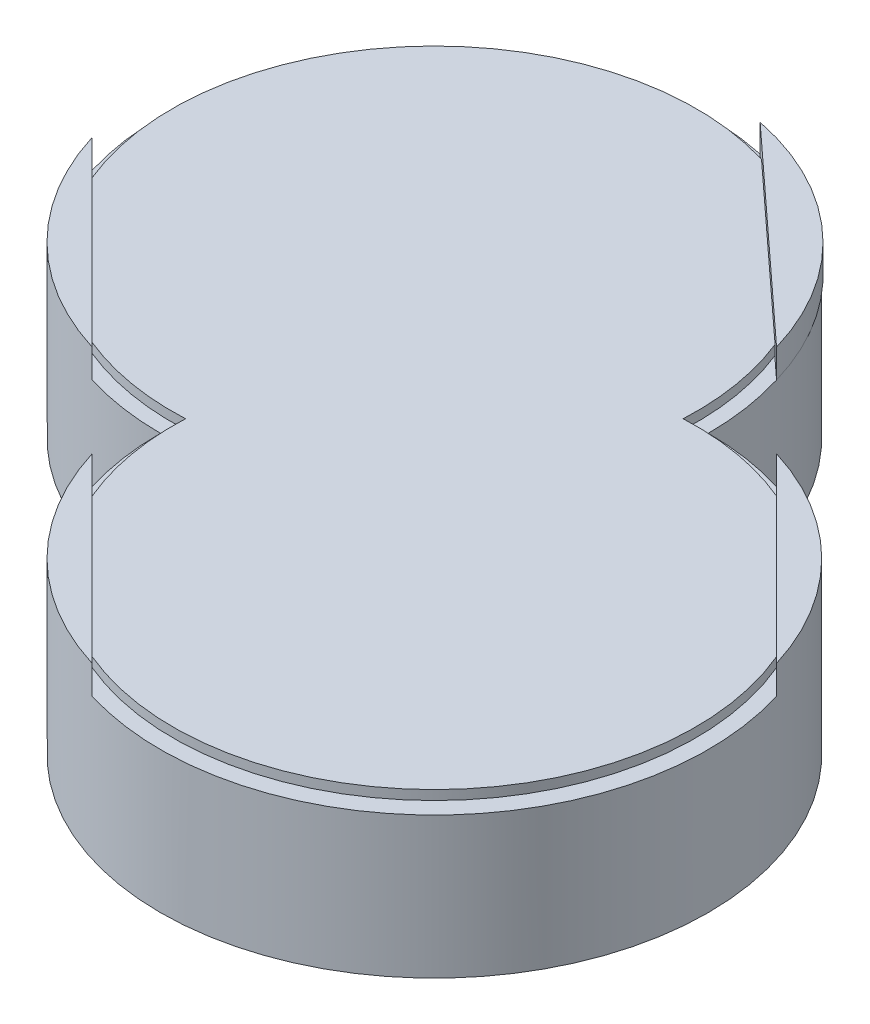
from build123d import *
from build123d.topology import SkipClean

# Parameters (mm, degrees)
BOSS_EXTRUDE1_DEPTH   = 24.13
SKETCH1_R             = 15.25707278
BOSS_EXTRUDE1_2_DEPTH = 24.13
SKETCH1_R_2           = 16.082263277
BOSS_EXTRUDE1_3_DEPTH = 24.13
BOSS_EXTRUDE2_START   = -6.096
BOSS_EXTRUDE2_DEPTH   = 6.096
BOSS_EXTRUDE3_DEPTH   = 6.096
CUT_EXTRUDE2_DEPTH    = 6.096
BOSS_EXTRUDE6_DEPTH   = 2.794
CUT_EXTRUDE3_DEPTH    = 0.762


with BuildPart() as part:
    # Sketch1 → Boss-Extrude1 (new body)
    with BuildSketch(Plane(origin=(0, 0, 0), x_dir=(1, 0, 0), z_dir=(0, 1, 0))):
        with BuildLine():
            ThreePointArc((0, 58.61646355), (-100.064562416, 100.064562416), (-58.61646355, 0))
            ThreePointArc((-58.61646355, 0), (41.448098866, -41.448098866), (0, 58.61646355))
        make_face()
        with BuildLine():
            ThreePointArc((0, 44.487942063), (31.457725514, -31.457725514), (-44.487942063, 0))
            Line((-44.487942063, 0), (-58.61646355, 14.199351912))
            ThreePointArc((-58.61646355, 14.199351912), (-90.024104391, 90.024104391), (-14.199351912, 58.61646355))
            Line((-14.199351912, 58.61646355), (0, 44.487942063))
        make_face(mode=Mode.SUBTRACT)
    extrude(amount=BOSS_EXTRUDE1_DEPTH)



with BuildPart() as body_2:
    # Sketch1 → Boss-Extrude1 2 (new body)
    with BuildSketch(Plane(origin=(0, 0, 0), x_dir=(1, 0, 0), z_dir=(0, 1, 0))):
        with Locations((-58.61646355, 58.61646355)):
            Circle(SKETCH1_R)
    extrude(amount=BOSS_EXTRUDE1_2_DEPTH)


with BuildPart() as body_3:
    # Sketch1 → Boss-Extrude1 3 (new body)
    with BuildSketch(Plane(origin=(0, 0, 0), x_dir=(1, 0, 0), z_dir=(0, 1, 0))):
        Circle(SKETCH1_R_2)
    extrude(amount=BOSS_EXTRUDE1_3_DEPTH)


with BuildPart() as part_1:
    add(part.part)

    add(body_2.part)  # Boss-Extrude2 merges body 2

    add(body_3.part)  # Boss-Extrude2 merges body 3
    # Sketch1_5 → Boss-Extrude2 (add)
    with BuildSketch(Plane(origin=(0, 0, 0), x_dir=(1, 0, 0), z_dir=(0, 1, 0)).offset(BOSS_EXTRUDE2_START)):
        with BuildLine():
            ThreePointArc((0, 58.61646355), (-100.064562416, 100.064562416), (-58.61646355, 0))
            ThreePointArc((-58.61646355, 0), (41.448098866, -41.448098866), (0, 58.61646355))
        make_face()
    extrude(amount=BOSS_EXTRUDE2_DEPTH)

    # Sketch5 → Boss-Extrude3 (add)
    with SkipClean():  # the faces are left unmerged after this step: merging them gives an invalid solid
        with BuildSketch(Plane(origin=(0, 24.13, 0), x_dir=(1, 0, 0), z_dir=(0, 1, 0))):
            with BuildLine():
                Line((-114.656096447, 41.427823582), (-75.805103519, 2.576830654))
                ThreePointArc((-75.805103519, 2.576830654), (-100.064562416, 17.168364685), (-114.656096447, 41.427823582))
            make_face()
            with BuildLine():
                Line((17.188639969, 56.039632897), (56.039632897, 17.188639969))
                ThreePointArc((56.039632897, 17.188639969), (41.448098866, 41.448098866), (17.188639969, 56.039632897))
            make_face()
            with BuildLine():
                Line((-45.993671494, 115.704154646), (-2.576830654, 75.805103519))
                ThreePointArc((-2.576830654, 75.805103519), (-18.713405445, 101.817729032), (-45.993671494, 115.704154646))
            make_face()
            with BuildLine():
                Line((-17.188639969, -56.039632897), (-56.039632897, -17.188639969))
                ThreePointArc((-56.039632897, -17.188639969), (-41.448098866, -41.448098866), (-17.188639969, -56.039632897))
            make_face()
        extrude(amount=BOSS_EXTRUDE3_DEPTH)

    # Sketch6 → Cut-Extrude2 (cut)
    with SkipClean():  # the faces are left unmerged after this step: merging them gives an invalid solid
        with BuildSketch(Plane(origin=(0, 24.13, 0), x_dir=(1, 0, 0), z_dir=(0, 1, 0))):
            with BuildLine():
                ThreePointArc((-9.489981352, 0), (-6.710430167, -6.710430167), (0, -9.489981352))
                ThreePointArc((0, -9.489981352), (5.668121673, -5.668121673), (9.489981352, 0))
                ThreePointArc((9.489981352, 0), (6.710430167, 6.710430167), (0, 9.489981352))
                ThreePointArc((0, 9.489981352), (-5.677482123, 5.677482123), (-9.489981352, 0))
            make_face()
            with BuildLine():
                ThreePointArc((-48.996622209, 58.61646355), (-51.814208504, 65.418718597), (-58.61646355, 68.236304892))
                ThreePointArc((-58.61646355, 68.236304892), (-64.379822748, 64.379822748), (-68.236304892, 58.61646355))
                ThreePointArc((-68.236304892, 58.61646355), (-65.418718597, 51.814208504), (-58.61646355, 48.996622209))
                ThreePointArc((-58.61646355, 48.996622209), (-52.847164261, 52.847164261), (-48.996622209, 58.61646355))
            make_face()
        extrude(amount=-CUT_EXTRUDE2_DEPTH, mode=Mode.SUBTRACT)

    # Sketch7 → Boss-Extrude6 (add)
    with SkipClean():  # the faces are left unmerged after this step: merging them gives an invalid solid
        with BuildSketch(Plane(origin=(0, 24.13, 0), x_dir=(1, 0, 0), z_dir=(0, 1, 0))):
            with BuildLine():
                ThreePointArc((-55.830465051, 2.585437245), (39.520408105, -39.520408105), (-2.585437245, 55.830465051))
                ThreePointArc((-2.585437245, 55.830465051), (-98.285328524, 98.285328524), (-55.830465051, 2.585437245))
            make_face()
        extrude(amount=BOSS_EXTRUDE6_DEPTH)

    # Sketch7_3 → Cut-Extrude3 (cut)
    with SkipClean():  # the faces are left unmerged after this step: merging them gives an invalid solid
        with BuildSketch(Plane(origin=(0, 24.13, 0), x_dir=(1, 0, 0), z_dir=(0, 1, 0))):
            with BuildLine():
                ThreePointArc((-55.830465051, 2.585437245), (39.520408105, -39.520408105), (-2.585437245, 55.830465051))
                ThreePointArc((-2.585437245, 55.830465051), (-98.285328524, 98.285328524), (-55.830465051, 2.585437245))
            make_face()
        extrude(amount=CUT_EXTRUDE3_DEPTH, mode=Mode.SUBTRACT)


solid = part_1.part
